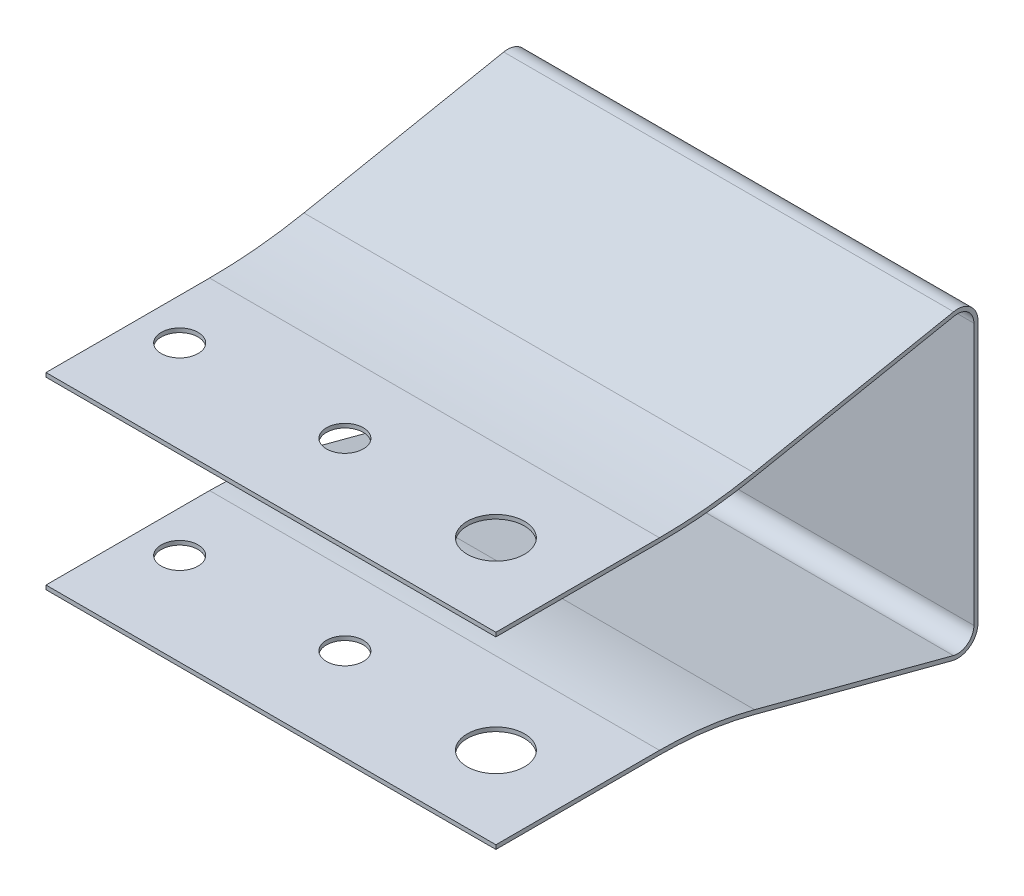
from build123d import *

# Parameters (mm, degrees)
EXTRUDE1_DEPTH          = 13.75
SKETCH2_R               = 1.75
SKETCH2_R_2             = 1.125
CUT_EXTRUDE1_DEPTH      = 10.25
CUT_EXTRUDE1_DEPTH_BACK = 10.25


with BuildPart() as part:
    # Sketch1 → Extrude1 (new body, symmetric)
    with BuildSketch(Plane(origin=(0, 0, 0), x_dir=(0, 0, -1), z_dir=(1, 0, 0))):
        with BuildLine():
            Line((-24.22, 8), (-24.22, -8))
            ThreePointArc((-24.22, -8), (-23.830111825, -8.792315317), (-22.964472878, -8.966801888))
            Line((-22.964472878, -8.966801888), (-10.813561051, -5.755298505))
            ThreePointArc((-10.813561051, -5.755298505), (-7.931209986, -5.189614776), (-5, -5))
            Line((-5, -5), (5, -5))
            Line((5, -5), (5, -5.25))
            Line((5, -5.25), (-5, -5.25))
            ThreePointArc((-5, -5.25), (-7.899000655, -5.437531211), (-10.749679271, -5.996998977))
            Line((-10.749679271, -5.996998977), (-22.900591097, -9.208502359))
            ThreePointArc((-22.900591097, -9.208502359), (-23.982639781, -8.990394146), (-24.47, -8))
            Line((-24.47, -8), (-24.47, 8))
            ThreePointArc((-24.47, 8), (-24.013634161, 8.965735377), (-22.97776829, 9.226304937))
            Line((-22.97776829, 9.226304937), (-10.765114709, 6.8139425))
            ThreePointArc((-10.765114709, 6.8139425), (-7.896315709, 6.391321284), (-5, 6.25))
            Line((-5, 6.25), (5, 6.25))
            Line((5, 6.25), (5, 6))
            Line((5, 6), (-5, 6))
            ThreePointArc((-5, 6), (-7.920654497, 6.142508858), (-10.813561051, 6.568681513))
            Line((-10.813561051, 6.568681513), (-23.026214632, 8.98104395))
            ThreePointArc((-23.026214632, 8.98104395), (-23.854907329, 8.772588302), (-24.22, 8))
        make_face()
    extrude(amount=EXTRUDE1_DEPTH, both=True)

    # Sketch2 → Cut-Extrude1 (cut, two sides)
    with BuildSketch(Plane(origin=(0, 0, 0), x_dir=(1, 0, 0), z_dir=(0, 1, 0))) as cut_extrude1_sk:
        with Locations(Location((8.75, 0, 0), (0, 0, 270))):  # turned: the seam where the file's is
            Circle(SKETCH2_R)
        with Locations(Location((-1.13, -0.65, 0), (0, 0, 270))):  # turned: the seam where the file's is
            Circle(SKETCH2_R_2)
        with Locations(Location((-11.23, -0.65, 0), (0, 0, 270))):  # turned: the seam where the file's is
            Circle(SKETCH2_R_2)
    extrude(amount=CUT_EXTRUDE1_DEPTH, mode=Mode.SUBTRACT)
    extrude(cut_extrude1_sk.sketch, amount=-CUT_EXTRUDE1_DEPTH_BACK, mode=Mode.SUBTRACT)


with BuildPart() as body_2:
    # Mirror1: mirrored copy
    add(part.part.mirror(Plane.XY))


solid = body_2.part
